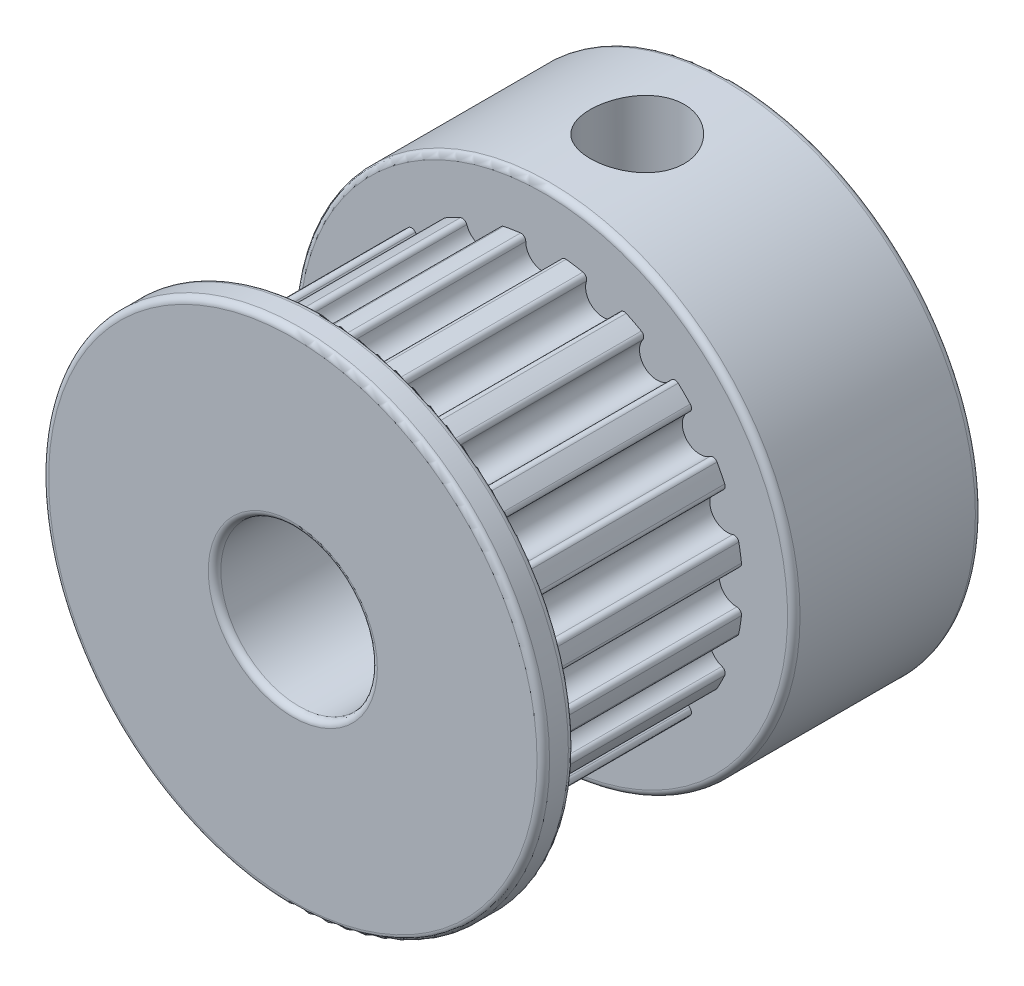
from build123d import *

# Parameters (mm, degrees)
IZIM1_R                        = 6.37
IZIM1_R_2                      = 2.5
Y_KSEKLIK_EKSTR_ZYON1_DEPTH    = 7
KES_EKSTR_ZYON2_DEPTH          = 7
RADYUS2_R                      = 0.15
DAIRESEL_KAPLAMA2_COUNT        = 20
RADYUS2_OF_DAIRESEL_KAPLAMA2_R = 0.15
IZIM4_R                        = 8
IZIM4_R_2                      = 2.5
Y_KSEKLIK_EKSTR_ZYON2_DEPTH    = 1
IZIM5_R                        = 8
IZIM5_R_2                      = 2.5
Y_KSEKLIK_EKSTR_ZYON4_DEPTH    = 6
RADYUS3_R                      = 0.2
IZIM6_R                        = 1.5
KES_EKSTR_ZYON3_DEPTH          = 10


with BuildPart() as part:
    # Çizim1 → Yükseklik-Ekstrüzyon1 (new body)
    with BuildSketch(Plane.XY):
        Circle(IZIM1_R)
        Circle(IZIM1_R_2, mode=Mode.SUBTRACT)
    extrude(amount=Y_KSEKLIK_EKSTR_ZYON1_DEPTH)

    # Çizim2 → Kes-Ekstrüzyon2 (cut)
    with BuildSketch(Plane.XY.offset(7)):
        with BuildLine():
            ThreePointArc((-0.53434772, 6.347548544), (0, 5.62), (0.53434772, 6.347548544))
            ThreePointArc((0.53434772, 6.347548544), (0, 6.37), (-0.53434772, 6.347548544))
        make_face()
    kes_ekstr_zyon2 = extrude(amount=-KES_EKSTR_ZYON2_DEPTH, mode=Mode.SUBTRACT)

    # Radyus2
    radyus2_edges = [part.edges().sort_by_distance(p)[0] for p in [
        (0.53434772, 6.347548544, 3.5),
        (-0.53434772, 6.347548544, 3.5),
    ]]
    fillet(radyus2_edges, radius=RADYUS2_R)

    # Dairesel Kaplama2: Kes-Ekstrüzyon2 ×20 about axis
    dairesel_kaplama2_axis = Axis((0, 0, 0), (0, 0, 1))
    for i in range(1, DAIRESEL_KAPLAMA2_COUNT):
        add(kes_ekstr_zyon2.rotate(dairesel_kaplama2_axis, i * 360 / DAIRESEL_KAPLAMA2_COUNT), mode=Mode.SUBTRACT)

    # Radyus2 of Dairesel Kaplama2
    radyus2_of_dairesel_kaplama2_edges = [part.edges().sort_by_distance(p)[0] for p in [
        (-1.453305492, 6.201999931, 3.5),
        (-2.469695253, 5.871754879, 3.5),
        (-3.298699036, 5.449356354, 3.5),
        (-4.163291808, 4.821192935, 3.5),
        (-4.821192935, 4.163291808, 3.5),
        (-5.449356354, 3.298699036, 3.5),
        (-5.871754879, 2.469695253, 3.5),
        (-6.201999931, 1.453305492, 3.5),
        (-6.347548544, 0.53434772, 3.5),
        (-6.347548544, -0.53434772, 3.5),
        (-6.201999931, -1.453305492, 3.5),
        (-5.871754879, -2.469695253, 3.5),
        (-5.449356354, -3.298699036, 3.5),
        (-4.821192935, -4.163291808, 3.5),
        (-4.163291808, -4.821192935, 3.5),
        (-3.298699036, -5.449356354, 3.5),
        (-2.469695253, -5.871754879, 3.5),
        (-1.453305492, -6.201999931, 3.5),
        (-0.53434772, -6.347548544, 3.5),
        (0.53434772, -6.347548544, 3.5),
        (1.453305492, -6.201999931, 3.5),
        (2.469695253, -5.871754879, 3.5),
        (3.298699036, -5.449356354, 3.5),
        (4.163291808, -4.821192935, 3.5),
        (4.821192935, -4.163291808, 3.5),
        (5.449356354, -3.298699036, 3.5),
        (5.871754879, -2.469695253, 3.5),
        (6.201999931, -1.453305492, 3.5),
        (6.347548544, -0.53434772, 3.5),
        (6.347548544, 0.53434772, 3.5),
        (6.201999931, 1.453305492, 3.5),
        (5.871754879, 2.469695253, 3.5),
        (5.449356354, 3.298699036, 3.5),
        (4.821192935, 4.163291808, 3.5),
        (4.163291808, 4.821192935, 3.5),
        (3.298699036, 5.449356354, 3.5),
        (2.469695253, 5.871754879, 3.5),
        (1.453305492, 6.201999931, 3.5),
    ]]
    fillet(radyus2_of_dairesel_kaplama2_edges, radius=RADYUS2_OF_DAIRESEL_KAPLAMA2_R)

    # Çizim4 → Yükseklik-Ekstrüzyon2 (add)
    with BuildSketch(Plane.XY.offset(7)):
        Circle(IZIM4_R)
        Circle(IZIM4_R_2, mode=Mode.SUBTRACT)
    extrude(amount=Y_KSEKLIK_EKSTR_ZYON2_DEPTH)

    # Çizim5 → Yükseklik-Ekstrüzyon4 (add)
    with BuildSketch(Plane(origin=(0, 0, 0), x_dir=(-1, 0, 0), z_dir=(0, 0, -1))):
        Circle(IZIM5_R)
        Circle(IZIM5_R_2, mode=Mode.SUBTRACT)
    extrude(amount=Y_KSEKLIK_EKSTR_ZYON4_DEPTH)

    # Radyus3
    radyus3_edges = [part.edges().sort_by_distance(p)[0] for p in [
        (-8, 0, 8),
        (-8, 0, 7),
        (-2.5, 0, 8),
        (8, 0, -6),
        (8, 0, 0),
        (2.5, 0, -6),
    ]]
    fillet(radyus3_edges, radius=RADYUS3_R)

    # Çizim6 → Kes-Ekstrüzyon3 (cut)
    with BuildSketch(Plane(origin=(0, 10, 0), x_dir=(1, 0, 0), z_dir=(0, 1, 0))):
        with Locations((0, 3)):
            Circle(IZIM6_R)
    extrude(amount=-KES_EKSTR_ZYON3_DEPTH, mode=Mode.SUBTRACT)


solid = part.part
